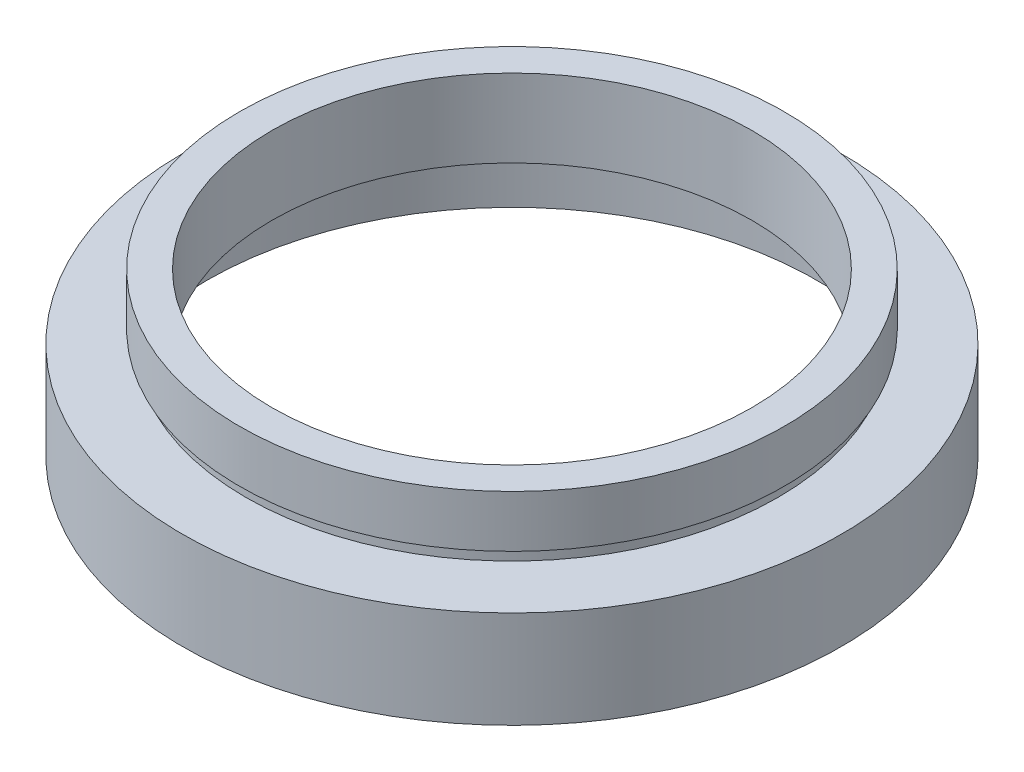
from build123d import *


with BuildPart() as part:
    # 草图1 → 旋转1 (revolve)
    with BuildSketch(Plane.XY, mode=Mode.PRIVATE) as revolve_1_sk:
        Polygon((23.5, 0), (23.5, 5.5), (24.1, 5.5), (24.1, 6.5), (18.5, 6.5), (18.5, 12.5), (21, 12.5), (21, 8.5), (20.5, 8.5), (20.5, 7.5), (25.4, 7.5), (25.4, 0), align=None)
    revolve(revolve_1_sk.sketch.rotate(Axis((0, 16.886018237, 0), (0, -1, 0)), 180), axis=Axis((0, 16.886018237, 0), (0, -1, 0)))  # turned: the seam where the file's is


solid = part.part
